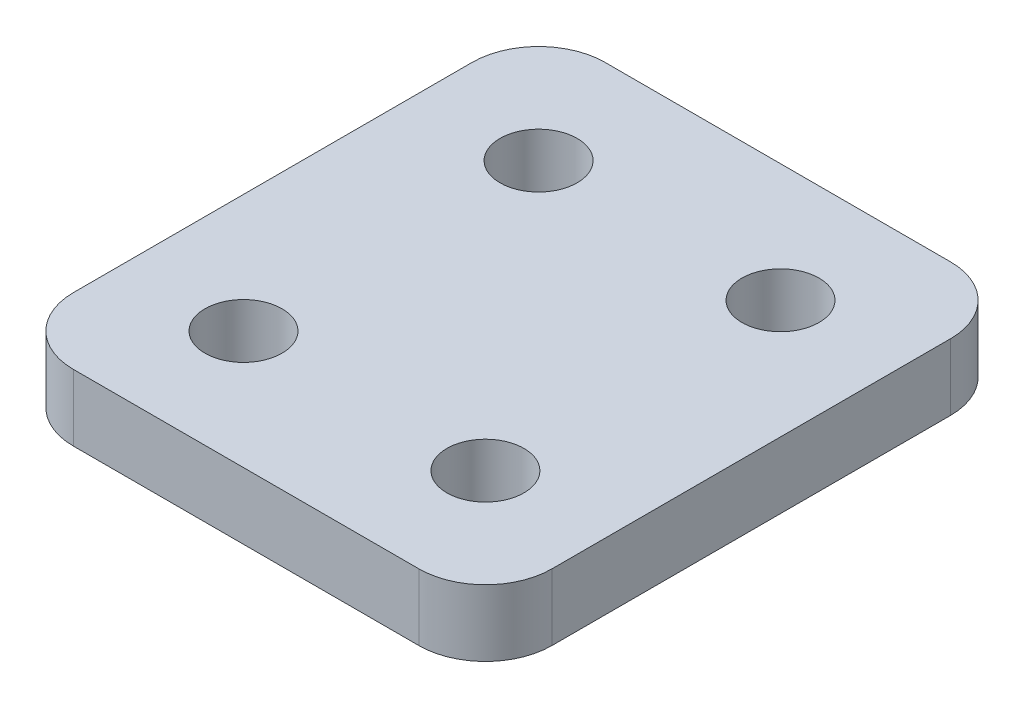
from build123d import *

# Parameters (mm, degrees)
SKETCH1_W           = 18.288
SKETCH1_H           = 20.32
BOSS_EXTRUDE1_DEPTH = 2.54
SKETCH2_R           = 1.4732
CUT_EXTRUDE1_DEPTH  = 3.54
FILLET1_R           = 2.54


with BuildPart() as part:
    # Sketch1 → Boss-Extrude1 (new body)
    with BuildSketch(Plane(origin=(0, 0, 0), x_dir=(1, 0, 0), z_dir=(0, 1, 0))):
        Rectangle(SKETCH1_W, SKETCH1_H)
    extrude(amount=BOSS_EXTRUDE1_DEPTH)

    # Sketch2 → Cut-Extrude1 (cut, through all)
    with BuildSketch(Plane(origin=(0, 2.54, 0), x_dir=(1, 0, 0), z_dir=(0, 1, 0))):
        with Locations((-4.6228, 5.6388)):
            Circle(SKETCH2_R)
        with Locations((-4.6228, -5.6388)):
            Circle(SKETCH2_R)
        with Locations((4.6228, -5.6388)):
            Circle(SKETCH2_R)
        with Locations((4.6228, 5.6388)):
            Circle(SKETCH2_R)
    extrude(amount=-CUT_EXTRUDE1_DEPTH, mode=Mode.SUBTRACT)

    # Fillet1
    fillet1_edges = [part.edges().sort_by_distance(p)[0] for p in [
        (9.144, 1.27, 10.16),
        (-9.144, 1.27, 10.16),
        (-9.144, 1.27, -10.16),
        (9.144, 1.27, -10.16),
    ]]
    fillet(fillet1_edges, radius=FILLET1_R)


solid = part.part
